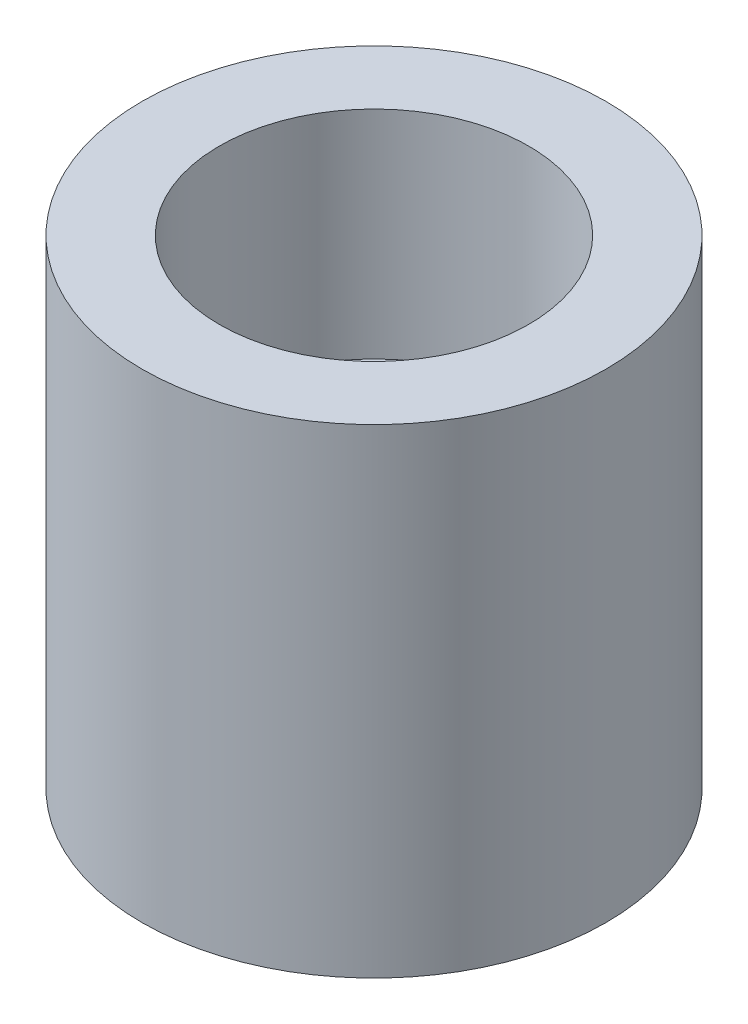
from build123d import *

# Parameters (mm, degrees)
SKETCH1_R           = 7.5
BOSS_EXTRUDE1_DEPTH = 15.5
SKETCH2_R           = 5
CUT_EXTRUDE1_DEPTH  = 7


with BuildPart() as part:
    # Sketch1 → Boss-Extrude1 (new body)
    with BuildSketch(Plane(origin=(0, 0, 0), x_dir=(1, 0, 0), z_dir=(0, 1, 0))):
        Circle(SKETCH1_R)
    extrude(amount=BOSS_EXTRUDE1_DEPTH)

    # Sketch2 → Cut-Extrude1 (cut)
    with BuildSketch(Plane(origin=(0, 15.5, 0), x_dir=(1, 0, 0), z_dir=(0, 1, 0))):
        Circle(SKETCH2_R)
    extrude(amount=-CUT_EXTRUDE1_DEPTH, mode=Mode.SUBTRACT)


solid = part.part
